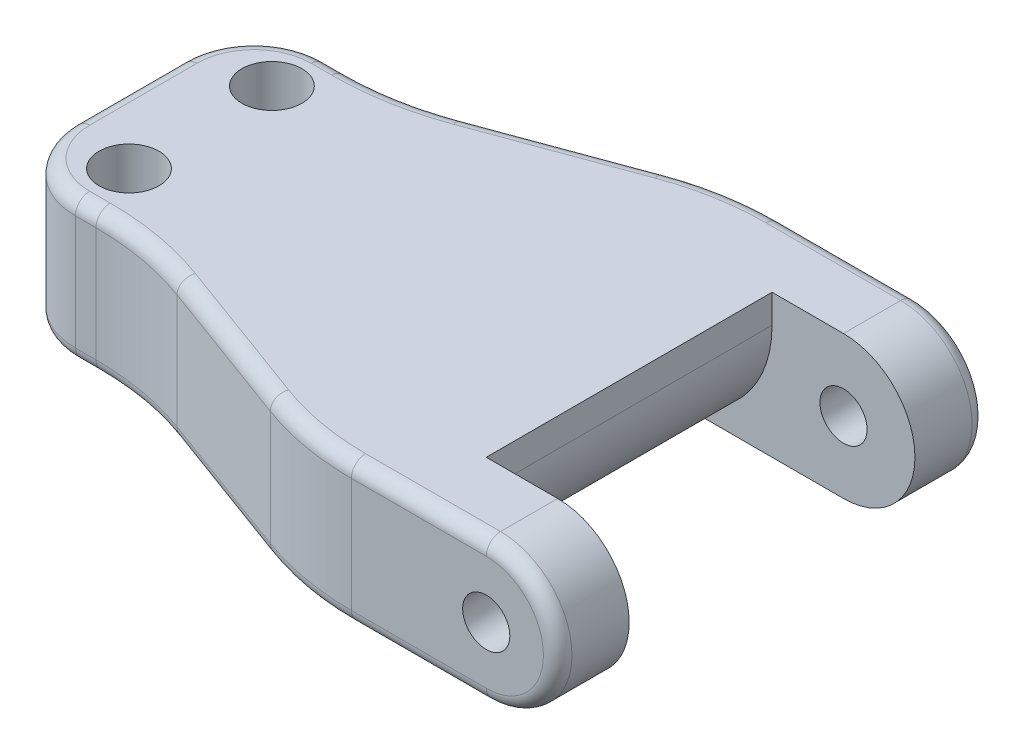
from build123d import *

# Parameters (mm, degrees)
SKETCH1_R           = 1.65
BOSS_EXTRUDE1_DEPTH = 15
CUT_EXTRUDE1_DEPTH  = 10
FILLET1_R           = 8
CUT_EXTRUDE2_DEPTH  = 11
SKETCH4_R           = 2.1
CUT_EXTRUDE3_DEPTH  = 3.5
FILLET2_R           = 5
FILLET3_R           = 20
FILLET5_R           = 1


with BuildPart() as part:
    # Sketch1 → Boss-Extrude1 (new body, symmetric)
    with BuildSketch(Plane.XY):
        with BuildLine():
            Line((0, 5), (-40, 5))
            Line((-40, 5), (-40, -5))
            Line((-40, -5), (0, -5))
            ThreePointArc((0, -5), (5, 0), (0, 5))
        make_face()
        Circle(SKETCH1_R, mode=Mode.SUBTRACT)
    extrude(amount=BOSS_EXTRUDE1_DEPTH, both=True)

    # Sketch2 → Cut-Extrude1 (cut, symmetric)
    with BuildSketch(Plane.XY):
        with BuildLine():
            Line((-5, 5), (0, 5))
            ThreePointArc((0, 5), (5, 0), (0, -5))
            Line((0, -5), (-5, -5))
            Line((-5, -5), (-5, 5))
        make_face()
    extrude(amount=CUT_EXTRUDE1_DEPTH, both=True, mode=Mode.SUBTRACT)

    # Fillet1
    fillet1_edges = [part.edges().sort_by_distance(p)[0] for p in [
        (-5, -5, 0),
    ]]
    fillet(fillet1_edges, radius=FILLET1_R)

    # Sketch3 → Cut-Extrude2 (cut, through all)
    with BuildSketch(Plane.XZ.offset(5)):
        Polygon((-40, 8.75), (-30, 8.75), (-13, 15), (-40, 15), align=None)
        Polygon((-13, -15), (-40, -15), (-40, -8.75), (-30, -8.75), align=None)
    extrude(amount=-CUT_EXTRUDE2_DEPTH, mode=Mode.SUBTRACT)

    # Sketch4 → Cut-Extrude3 (cut)
    with BuildSketch(Plane(origin=(0, 5, 0), x_dir=(1, 0, 0), z_dir=(0, 1, 0))):
        with Locations((-35, 5)):
            Circle(SKETCH4_R)
        with Locations((-35, -5)):
            Circle(SKETCH4_R)
    cut_extrude3 = extrude(amount=-CUT_EXTRUDE3_DEPTH, mode=Mode.SUBTRACT)

    # Fillet2
    fillet2_edges = [part.edges().sort_by_distance(p)[0] for p in [
        (-40, 0, 8.75),
        (-40, 0, -8.75),
    ]]
    fillet(fillet2_edges, radius=FILLET2_R)

    # Fillet3
    fillet3_edges = [part.edges().sort_by_distance(p)[0] for p in [
        (-13, 0, 15),
        (-30, 0, 8.75),
        (-30, 0, -8.75),
        (-13, 0, -15),
    ]]
    fillet(fillet3_edges, radius=FILLET3_R)

    # Fillet5
    fillet5_edges = [part.edges().sort_by_distance(p)[0] for p in [
        (-34.279993099, -5, 8.75),
        (-34.279993099, 5, 8.75),
        (-40, -5, 0),
        (-38.535533906, -5, -7.285533906),
        (-38.535533906, -5, 7.285533906),
        (-40, 5, 0),
        (-38.535533906, 5, -7.285533906),
        (-38.535533906, 5, 7.285533906),
        (-21.5, -5, -11.875),
        (-21.5, 5, -11.875),
        (-34.279993099, -5, -8.75),
        (-4.720006901, -5, -15),
        (-4.720006901, -5, 15),
        (-21.5, -5, 11.875),
        (-12.944908854, -5, 14.690497979),
        (-12.944908854, -5, -14.690497979),
        (-21.5, 5, 11.875),
        (-34.279993099, 5, -8.75),
        (-12.944908854, 5, 14.690497979),
        (-12.944908854, 5, -14.690497979),
        (-30.055091146, -5, -9.059502021),
        (-30.055091146, 5, -9.059502021),
        (-30.055091146, -5, 9.059502021),
        (-30.055091146, 5, 9.059502021),
        (5, 0, 15),
        (-4.720006901, 5, -15),
        (5, 0, -15),
        (-4.720006901, 5, 15),
    ]]
    fillet(fillet5_edges, radius=FILLET5_R)

    # Mirror1: Cut-Extrude3 across plane
    add(cut_extrude3.mirror(Plane.ZX), mode=Mode.SUBTRACT)


solid = part.part
